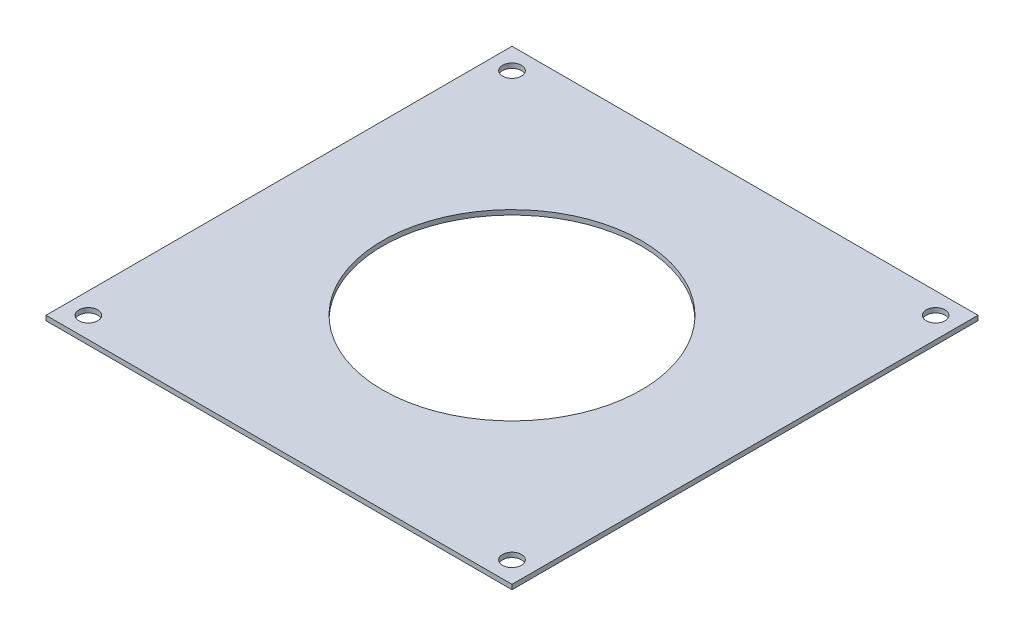
from build123d import *

# Parameters (mm, degrees)
SKETCH1_W           = 98.782817332
SKETCH1_H           = 98.782817332
BOSS_EXTRUDE1_DEPTH = 1.000000032
SKETCH3_R           = 2.000000064
CUT_EXTRUDE2_DEPTH  = 2.000000032
SKETCH4_R           = 27.432
CUT_EXTRUDE3_DEPTH  = 2.000000032


with BuildPart() as part:
    # Sketch1 → Boss-Extrude1 (new body)
    with BuildSketch(Plane(origin=(0, 0, 0), x_dir=(1, 0, 0), z_dir=(0, 1, 0))):
        Rectangle(SKETCH1_W, SKETCH1_H)
    extrude(amount=BOSS_EXTRUDE1_DEPTH)

    # Sketch3 → Cut-Extrude2 (cut, through all)
    with BuildSketch(Plane(origin=(0, 0, 0), x_dir=(1, 0, 0), z_dir=(0, 1, 0))):
        with Locations((44.901280605, 44.901280605)):
            Circle(SKETCH3_R)
        with Locations((44.901280605, -44.901280605)):
            Circle(SKETCH3_R)
        with Locations((-44.901280605, -44.901280605)):
            Circle(SKETCH3_R)
        with Locations((-44.901280605, 44.901280605)):
            Circle(SKETCH3_R)
    extrude(amount=CUT_EXTRUDE2_DEPTH, mode=Mode.SUBTRACT)

    # Sketch4 → Cut-Extrude3 (cut, through all)
    with BuildSketch(Plane(origin=(0, 0, 0), x_dir=(1, 0, 0), z_dir=(0, 1, 0))):
        Circle(SKETCH4_R)
    extrude(amount=CUT_EXTRUDE3_DEPTH, mode=Mode.SUBTRACT)


solid = part.part
